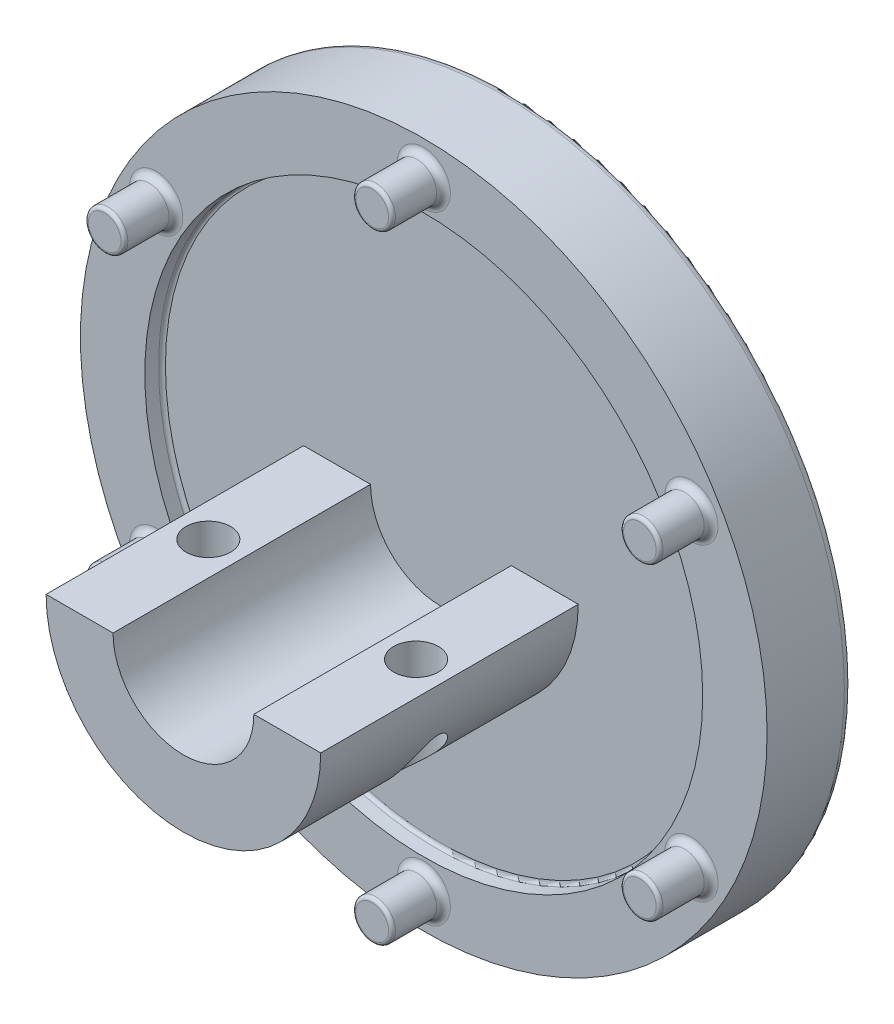
from build123d import *

# Parameters (mm, degrees)
SKETCH1_R           = 20
BOSS_EXTRUDE1_DEPTH = 5
SKETCH3_R           = 1.15
BOSS_EXTRUDE3_DEPTH = 3
FILLET1_R           = 0.4
SKETCH4_R           = 8.5
CUT_EXTRUDE2_DEPTH  = 1.5
SKETCH6_R           = 5
BOSS_EXTRUDE4_DEPTH = 0.5
SKETCH7_R           = 3.85
BOSS_EXTRUDE6_DEPTH = 4.5
FILLET2_R           = 0.5
FILLET3_R           = 0.5
FILLET4_R           = 0.5
FILLET5_R           = 0.2
SKETCH8_R           = 16.25
CUT_EXTRUDE4_DEPTH  = 1
FILLET6_R           = 0.2
BOSS_EXTRUDE7_DEPTH = 15
SKETCH11_R          = 1.3
CUT_EXTRUDE5_DEPTH  = 21.0000001


with BuildPart() as part:
    # Sketch1 → Boss-Extrude1 (new body)
    with BuildSketch(Plane.XY):
        Circle(SKETCH1_R)
    extrude(amount=BOSS_EXTRUDE1_DEPTH)

    # Sketch3 → Boss-Extrude3 (add)
    with BuildSketch(Plane.XY.offset(5)):
        with Locations((0, 18)):
            Circle(SKETCH3_R)
        with Locations((15.588457268, 9)):
            Circle(SKETCH3_R)
        with Locations((15.588457268, -9)):
            Circle(SKETCH3_R)
        with Locations((0, -18)):
            Circle(SKETCH3_R)
        with Locations((-15.588457268, -9)):
            Circle(SKETCH3_R)
        with Locations((-15.588457268, 9)):
            Circle(SKETCH3_R)
    extrude(amount=BOSS_EXTRUDE3_DEPTH)

    # Fillet1
    fillet1_edges = [part.edges().sort_by_distance(p)[0] for p in [
        (14.438457268, -9, 5),
        (-1.15, -18, 5),
        (-16.738457268, -9, 5),
        (-16.738457268, 9, 5),
        (-1.15, 18, 5),
        (14.438457268, 9, 5),
    ]]
    fillet(fillet1_edges, radius=FILLET1_R)

    # Sketch4 → Cut-Extrude2 (cut)
    with BuildSketch(Plane(origin=(0, 0, 0), x_dir=(-1, 0, 0), z_dir=(0, 0, -1))):
        Circle(SKETCH4_R)
    extrude(amount=-CUT_EXTRUDE2_DEPTH, mode=Mode.SUBTRACT)

    # Sketch6 → Boss-Extrude4 (add)
    with BuildSketch(Plane(origin=(0, 0, 1.5), x_dir=(-1, 0, 0), z_dir=(0, 0, -1))):
        Circle(SKETCH6_R)
    extrude(amount=BOSS_EXTRUDE4_DEPTH)

    # Sketch7 → Boss-Extrude6 (add)
    with BuildSketch(Plane(origin=(0, 0, 1), x_dir=(-1, 0, 0), z_dir=(0, 0, -1))):
        Circle(SKETCH7_R)
    extrude(amount=BOSS_EXTRUDE6_DEPTH)

    # Fillet2
    fillet2_edges = [part.edges().sort_by_distance(p)[0] for p in [
        (-20, 0, 0),
    ]]
    fillet(fillet2_edges, radius=FILLET2_R)

    # Fillet3
    fillet3_edges = [part.edges().sort_by_distance(p)[0] for p in [
        (8.5, 0, 0),
    ]]
    fillet(fillet3_edges, radius=FILLET3_R)

    # Fillet4
    fillet4_edges = [part.edges().sort_by_distance(p)[0] for p in [
        (3.85, 0, -3.5),
    ]]
    fillet(fillet4_edges, radius=FILLET4_R)

    # Fillet5
    fillet5_edges = [part.edges().sort_by_distance(p)[0] for p in [
        (14.438457268, -9, 8),
        (-1.15, -18, 8),
        (-16.738457268, -9, 8),
        (-16.738457268, 9, 8),
        (-1.15, 18, 8),
        (14.438457268, 9, 8),
    ]]
    fillet(fillet5_edges, radius=FILLET5_R)

    # Sketch8 → Cut-Extrude4 (cut)
    with BuildSketch(Plane.XY.offset(5)):
        Circle(SKETCH8_R)
    extrude(amount=-CUT_EXTRUDE4_DEPTH, mode=Mode.SUBTRACT)

    # Fillet6
    fillet6_edges = [part.edges().sort_by_distance(p)[0] for p in [
        (-16.25, 0, 4),
    ]]
    fillet(fillet6_edges, radius=FILLET6_R)

    # Sketch9 → Boss-Extrude7 (add)
    with BuildSketch(Plane.XY.offset(4)):
        with BuildLine():
            Line((-4.1, 0), (-8, 0))
            ThreePointArc((-8, 0), (0, -8), (8, 0))
            Line((8, 0), (4.1, 0))
            ThreePointArc((4.1, 0), (0, -4.1), (-4.1, 0))
        make_face()
    extrude(amount=BOSS_EXTRUDE7_DEPTH)

    # Sketch11 → Cut-Extrude5 (cut, through all)
    with BuildSketch(Plane(origin=(0, 0, 0), x_dir=(1, 0, 0), z_dir=(0, 1, 0))):
        with Locations((-6.05, -11.5)):
            Circle(SKETCH11_R)
        with Locations((6.05, -11.5)):
            Circle(SKETCH11_R)
    extrude(amount=-CUT_EXTRUDE5_DEPTH, mode=Mode.SUBTRACT)


solid = part.part
